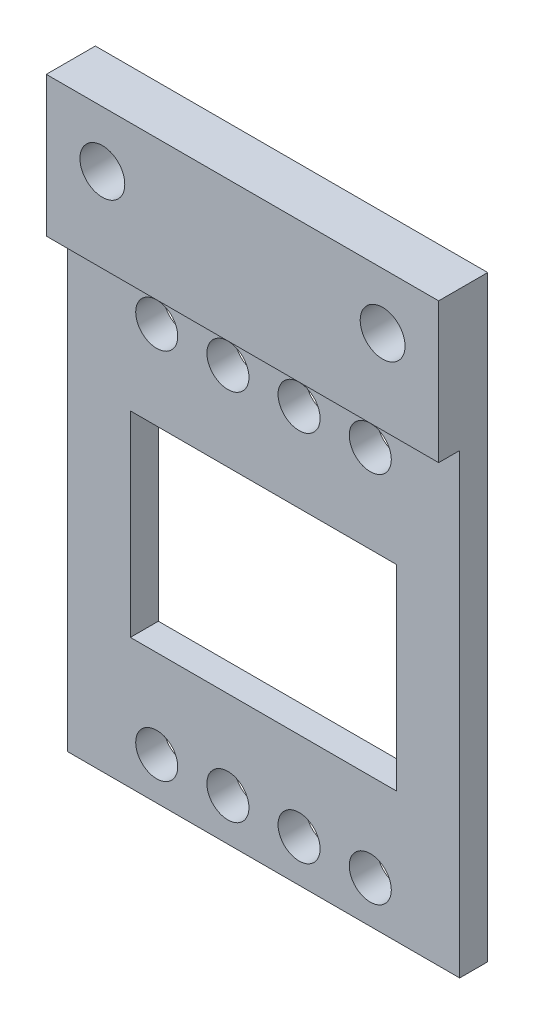
from build123d import *

# Parameters (mm, degrees)
SKETCH1_W                   = 14
SKETCH1_H                   = 16.3
SKETCH1_W_2                 = 10
SKETCH1_H_2                 = 13.3
SKETCH1_W_3                 = 9.5
SKETCH1_H_3                 = 7
CAP_EXTRUDE_DEPTH           = 1
SKETCH1_7_W                 = 14
SKETCH1_7_H                 = 5
FLAP_EXTRUDE_DEPTH          = 1.75
CUT_EXTRUDE2_REACH          = 3.75
SKETCH1_9_W                 = 9.5
SKETCH1_9_H                 = 7
F_1_5MM_DOWEL_HOLE1_D       = 1.5
F_1_5MM_DOWEL_HOLE1_DEPTH   = 1
TAP_DRILL_FOR_M2_TAP1_D     = 1.6
TAP_DRILL_FOR_M2_TAP1_DEPTH = 1.75


with BuildPart() as part:
    # Sketch1 → cap_extrude (new body)
    with BuildSketch(Plane.XY):
        Rectangle(SKETCH1_W, SKETCH1_H)
        Rectangle(SKETCH1_W_2, SKETCH1_H_2, mode=Mode.SUBTRACT)
        Rectangle(SKETCH1_W_2, SKETCH1_H_2)
        Rectangle(SKETCH1_W_3, SKETCH1_H_3, mode=Mode.SUBTRACT)
        Rectangle(SKETCH1_W_3, SKETCH1_H_3)
    extrude(amount=CAP_EXTRUDE_DEPTH)

    # Sketch1_7 → flap_extrude (add)
    with BuildSketch(Plane.XY):
        with Locations((0, 10.65)):
            Rectangle(SKETCH1_7_W, SKETCH1_7_H)
    extrude(amount=FLAP_EXTRUDE_DEPTH)

    # Sketch1_9 → Cut-Extrude2 (cut, up to next)
    with BuildSketch(Plane.XY, mode=Mode.PRIVATE) as cut_extrude2_sk1:
        Rectangle(SKETCH1_9_W, SKETCH1_9_H)
    cut_extrude2_tool1 = extrude(cut_extrude2_sk1.sketch, amount=CUT_EXTRUDE2_REACH, mode=Mode.PRIVATE) & part.part
    add(cut_extrude2_tool1.solids().sort_by_distance((0, 0, 0))[0], mode=Mode.SUBTRACT)

    # Ø1.5mm Dowel Hole1
    with Locations(Plane(origin=(0, 0, 0), x_dir=(-1, 0, 0), z_dir=(0, 0, -1))):
        with Locations((3.81, 6.65), (1.27, 6.65), (-1.27, 6.65), (-3.81, 6.65), (-3.81, -6.65), (-1.27, -6.65), (1.27, -6.65), (3.81, -6.65)):
            Hole(F_1_5MM_DOWEL_HOLE1_D / 2, depth=F_1_5MM_DOWEL_HOLE1_DEPTH)

    # Tap Drill for M2 Tap1
    with Locations(Plane(origin=(0, 0, 0), x_dir=(-1, 0, 0), z_dir=(0, 0, -1))):
        with Locations((-5, 11.15), (5, 11.15)):
            Hole(TAP_DRILL_FOR_M2_TAP1_D / 2, depth=TAP_DRILL_FOR_M2_TAP1_DEPTH)


solid = part.part
